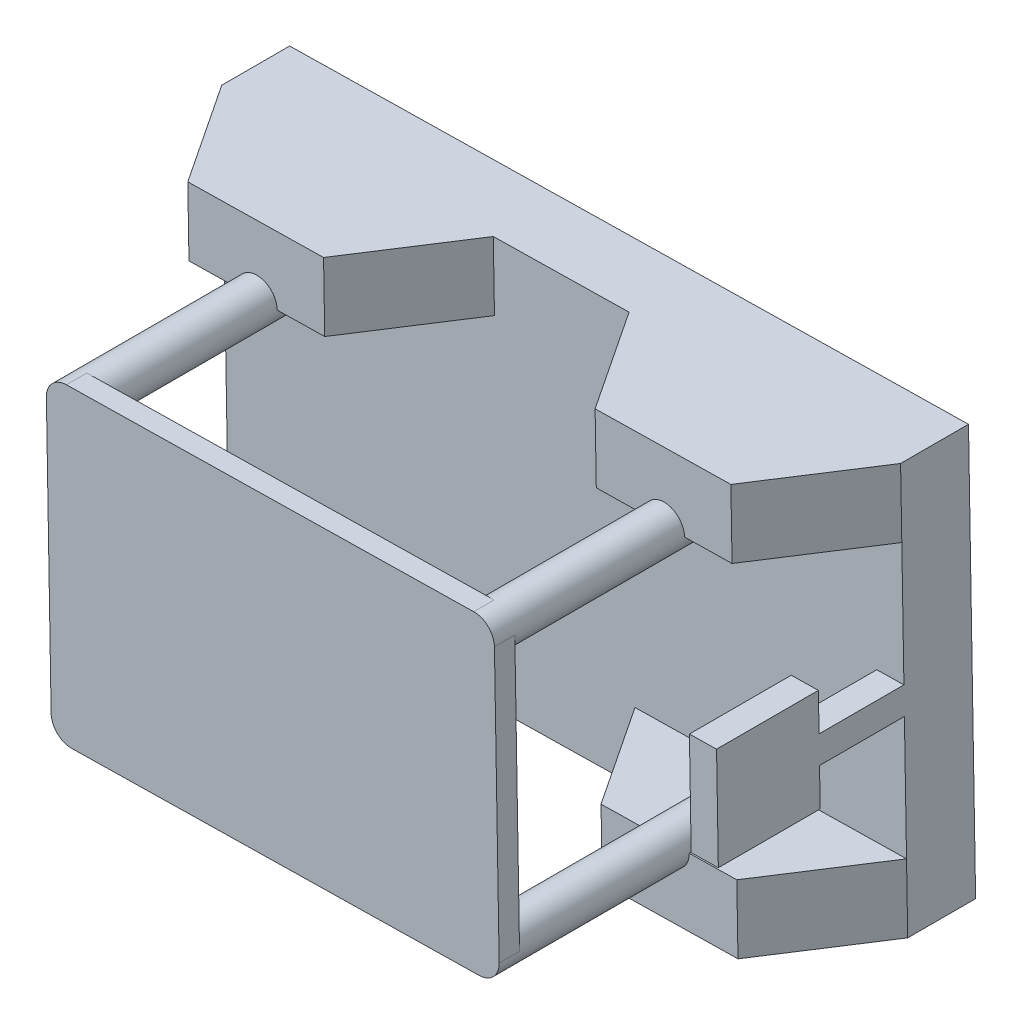
from build123d import *

# Parameters (mm, degrees)
SKETCH3_W             = 300
SKETCH3_H             = 500
BOSS_EXTRUDE2_DEPTH   = 50
BOSS_EXTRUDE3_DEPTH   = 50
BOSS_EXTRUDE4_DEPTH   = 50
SKETCH7_R             = 15
BOSS_EXTRUDE5_DEPTH   = 200
BOSS_EXTRUDE6_DEPTH   = 15
SKETCH9_W             = 20
SKETCH9_H             = 20
BOSS_EXTRUDE7_DEPTH   = 100
SKETCH10_W            = 75
SKETCH10_H            = 75
BOSS_EXTRUDE8_DEPTH   = 20
BODY_MOVE_COPY1_ANGLE = 89


with BuildPart() as part:
    # Sketch3 → Boss-Extrude2 (new body)
    with BuildSketch(Plane.XY):
        Rectangle(SKETCH3_W, SKETCH3_H)
    extrude(amount=BOSS_EXTRUDE2_DEPTH)

    # Sketch5 → Boss-Extrude3 (add)
    with BuildSketch(Plane.ZY.offset(150)):
        Polygon((50, 250), (125, 200), (125, 100), (50, 50), align=None)
        Polygon((50, -50), (50, -250), (125, -200), (125, -100), align=None)
    extrude(amount=-BOSS_EXTRUDE3_DEPTH)

    # Sketch6 → Boss-Extrude4 (add)
    with BuildSketch(Plane(origin=(150, 0, 0), x_dir=(0, 0, -1), z_dir=(1, 0, 0))):
        Polygon((-50, -250), (-50, -50), (-125, -100), (-125, -200), align=None)
        Polygon((-50, 250), (-125, 200), (-125, 100), (-50, 50), align=None)
    extrude(amount=-BOSS_EXTRUDE4_DEPTH)

    # Sketch7 → Boss-Extrude5 (add)
    with BuildSketch(Plane.XY.offset(50)):
        with Locations((-100, 150)):
            Circle(SKETCH7_R)
        with Locations((100, 150)):
            Circle(SKETCH7_R)
        with Locations((-100, -150)):
            Circle(SKETCH7_R)
        with Locations((100, -150)):
            Circle(SKETCH7_R)
    extrude(amount=BOSS_EXTRUDE5_DEPTH)

    # Sketch8 → Boss-Extrude6 (add)
    with BuildSketch(Plane.XY.offset(250)):
        with BuildLine():
            Line((-115, 150.000000362), (-115, -150))
            ThreePointArc((-115, -150), (-110.606601718, -160.606601718), (-100, -165))
            Line((-100, -165), (100.000000138, -165))
            ThreePointArc((100.000000138, -165), (110.606601767, -160.606601669), (115, -150))
            Line((115, -150), (115, 150))
            ThreePointArc((115, 150), (110.606601718, 160.606601718), (100, 165))
            Line((100, 165), (-100, 165))
            ThreePointArc((-100, 165), (-110.60660159, 160.606601846), (-115, 150.000000362))
        make_face()
    extrude(amount=BOSS_EXTRUDE6_DEPTH)

    # Sketch9 → Boss-Extrude7 (add)
    with BuildSketch(Plane.XY.offset(50)):
        with Locations((0, 240)):
            Rectangle(SKETCH9_W, SKETCH9_H)
    extrude(amount=BOSS_EXTRUDE7_DEPTH)

    # Sketch10 → Boss-Extrude8 (add)
    with BuildSketch(Plane(origin=(0, 250, 0), x_dir=(1, 0, 0), z_dir=(0, 1, 0))):
        with Locations((0, -150)):
            Rectangle(SKETCH10_W, SKETCH10_H)
    extrude(amount=-BOSS_EXTRUDE8_DEPTH)


with BuildPart() as part_1:
    # Body-Move/Copy1: moved
    add(part.part.rotate(Axis((0, 0, 0), (0, 0, -1)), BODY_MOVE_COPY1_ANGLE))


solid = part_1.part
